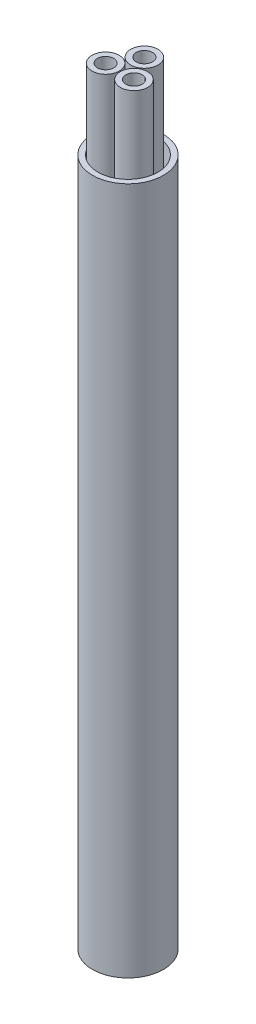
from build123d import *

# Parameters (mm, degrees)
SKETCH1_R             = 1.25
SKETCH1_R_2           = 0.75
BOSS_EXTRUDE1_DEPTH   = 70
BOSS_EXTRUDE1_2_DEPTH = 70
BOSS_EXTRUDE1_3_DEPTH = 70
SKETCH1_3_R           = 3.2511107
BOSS_EXTRUDE2_DEPTH   = 63


with BuildPart() as part:
    # Sketch1 → Boss-Extrude1 (new body)
    with BuildSketch(Plane(origin=(0, 0, 0), x_dir=(1, 0, 0), z_dir=(0, 1, 0))):
        with Locations((-1.3, -0.75055535)):
            Circle(SKETCH1_R)
        with Locations((-1.3, -0.75055535)):
            Circle(SKETCH1_R_2, mode=Mode.SUBTRACT)
    extrude(amount=BOSS_EXTRUDE1_DEPTH)


with BuildPart() as body_2:
    # Sketch1 → Boss-Extrude1 2 (new body)
    with BuildSketch(Plane(origin=(0, 0, 0), x_dir=(1, 0, 0), z_dir=(0, 1, 0))):
        with Locations((1.3, -0.75055535)):
            Circle(SKETCH1_R)
        with Locations((1.3, -0.75055535)):
            Circle(SKETCH1_R_2, mode=Mode.SUBTRACT)
    extrude(amount=BOSS_EXTRUDE1_2_DEPTH)


with BuildPart() as body_3:
    # Sketch1 → Boss-Extrude1 3 (new body)
    with BuildSketch(Plane(origin=(0, 0, 0), x_dir=(1, 0, 0), z_dir=(0, 1, 0))):
        with Locations((0, 1.5011107)):
            Circle(SKETCH1_R)
        with Locations((0, 1.5011107)):
            Circle(SKETCH1_R_2, mode=Mode.SUBTRACT)
    extrude(amount=BOSS_EXTRUDE1_3_DEPTH)


with BuildPart() as body_4:
    # Sketch1_3 → Boss-Extrude2 (new body)
    with BuildSketch(Plane(origin=(0, 0, 0), x_dir=(1, 0, 0), z_dir=(0, 1, 0))):
        Circle(SKETCH1_3_R)
        with BuildLine():
            ThreePointArc((2.382531738, -1.375555379), (-8e-09, -2.7511107), (-2.382531746, -1.375555364))
            ThreePointArc((-2.382531746, -1.375555364), (-2.382531759, 1.375555343), (0, 2.7511107))
            ThreePointArc((0, 2.7511107), (1.945329032, 1.945329032), (2.7511107, 0))
            ThreePointArc((2.7511107, 0), (2.657368872, -0.71203986), (2.382531738, -1.375555379))
        make_face(mode=Mode.SUBTRACT)
    extrude(amount=BOSS_EXTRUDE2_DEPTH)


solid = Compound([part.part, body_2.part, body_3.part, body_4.part])
